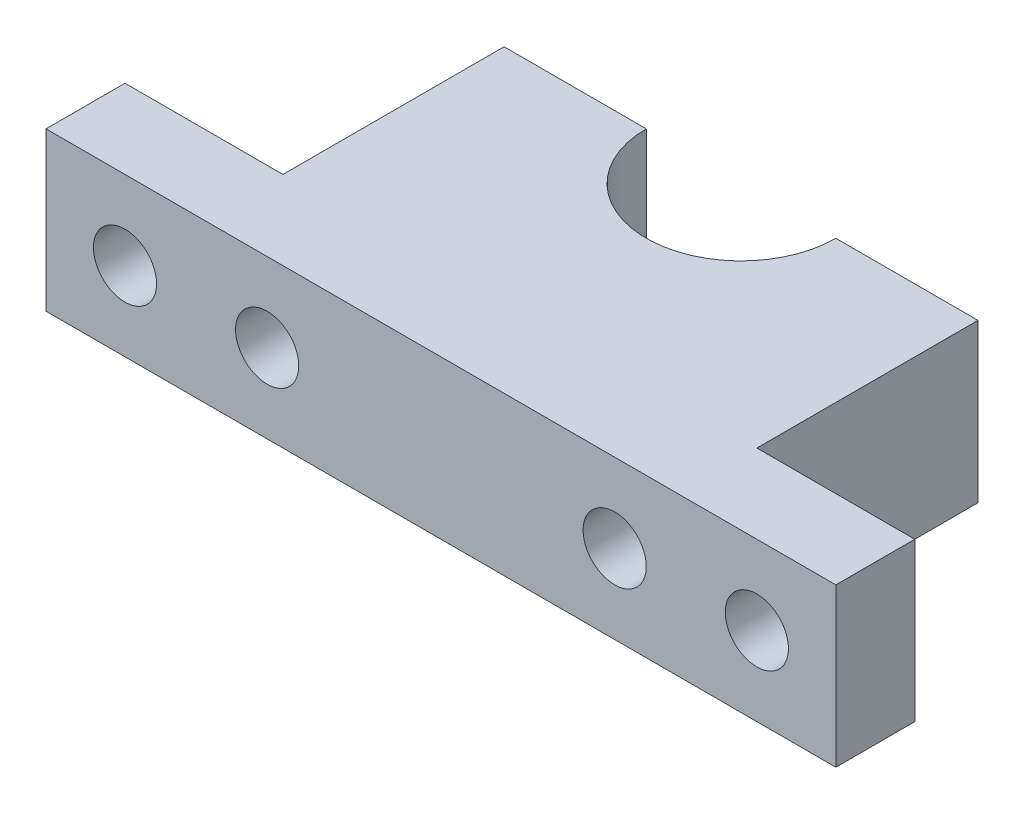
from build123d import *

# Parameters (mm, degrees)
BOSS_EXTRUDE1_DEPTH = 10
SKETCH2_R           = 2
CUT_EXTRUDE1_DEPTH  = 20


with BuildPart() as part:
    # Sketch1 → Boss-Extrude1 (new body)
    with BuildSketch(Plane(origin=(0, 0, 0), x_dir=(1, 0, 0), z_dir=(0, 1, 0))):
        with BuildLine():
            Line((25, 0), (-25, 0))
            Line((-25, 0), (-25, 5))
            Line((-25, 5), (-15, 5))
            Line((-15, 5), (-15, 19))
            Line((-15, 19), (-6, 19))
            ThreePointArc((-6, 19), (0, 13), (6, 19))
            Line((6, 19), (15, 19))
            Line((15, 19), (15, 5))
            Line((15, 5), (25, 5))
            Line((25, 5), (25, 0))
        make_face()
    extrude(amount=BOSS_EXTRUDE1_DEPTH)

    # Sketch2 → Cut-Extrude1 (cut, through all)
    with BuildSketch(Plane.XY):
        with Locations((-20, 5)):
            Circle(SKETCH2_R)
        with Locations((-11, 5)):
            Circle(SKETCH2_R)
        with Locations((20, 5)):
            Circle(SKETCH2_R)
        with Locations((11, 5)):
            Circle(SKETCH2_R)
    extrude(amount=-CUT_EXTRUDE1_DEPTH, mode=Mode.SUBTRACT)


solid = part.part
